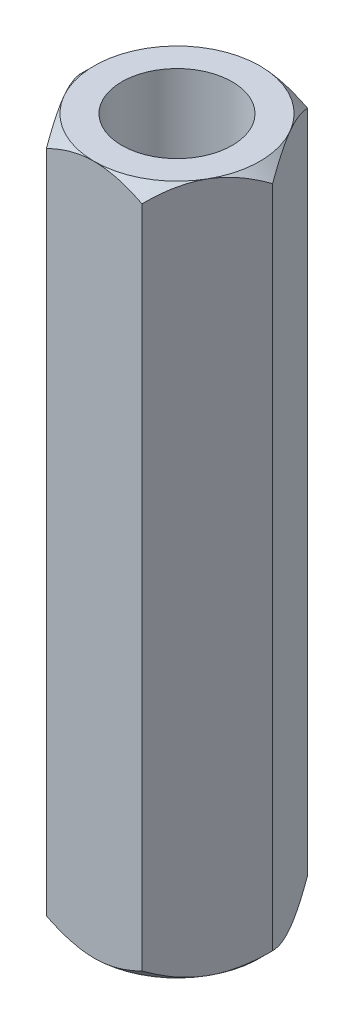
from build123d import *

# Parameters (mm, degrees)
SKETCH_1_R          = 3.5
SKETCH_1_R_2        = 2
EXTRUDE_1_DEPTH     = 25
CHAMFER_1_SIZE      = 0.5
SKETCH_2_OUTSIDE_W  = 14.378
SKETCH_2_OUTSIDE_H  = 14.378
CUT_EXTRUDE_1_DEPTH = 26


with BuildPart() as part:
    # 草图1 → 凸台-拉伸1 (new body)
    with BuildSketch(Plane(origin=(0, 0, 0), x_dir=(1, 0, 0), z_dir=(0, 1, 0))):
        Circle(SKETCH_1_R)
        Circle(SKETCH_1_R_2, mode=Mode.SUBTRACT)
    extrude(amount=EXTRUDE_1_DEPTH)

    # 倒角1
    chamfer_1_edges = [part.edges().sort_by_distance(p)[0] for p in [
        (-3.5, 0, 0),
        (-3.5, 25, 0),
    ]]
    chamfer(chamfer_1_edges, length=CHAMFER_1_SIZE)

    # 草图2 outside → 切除-拉伸1 (cut, through all)
    with BuildSketch(Plane(origin=(0, 25, 0), x_dir=(1, 0, 0), z_dir=(0, 1, 0))):
        Rectangle(SKETCH_2_OUTSIDE_W, SKETCH_2_OUTSIDE_H)
        Polygon((1.732050808, 3), (-1.732050808, 3), (-3.464101615, 0), (-1.732050808, -3), (1.732050808, -3), (3.464101615, 0), align=None, mode=Mode.SUBTRACT)
    extrude(amount=-CUT_EXTRUDE_1_DEPTH, mode=Mode.SUBTRACT)


solid = part.part
